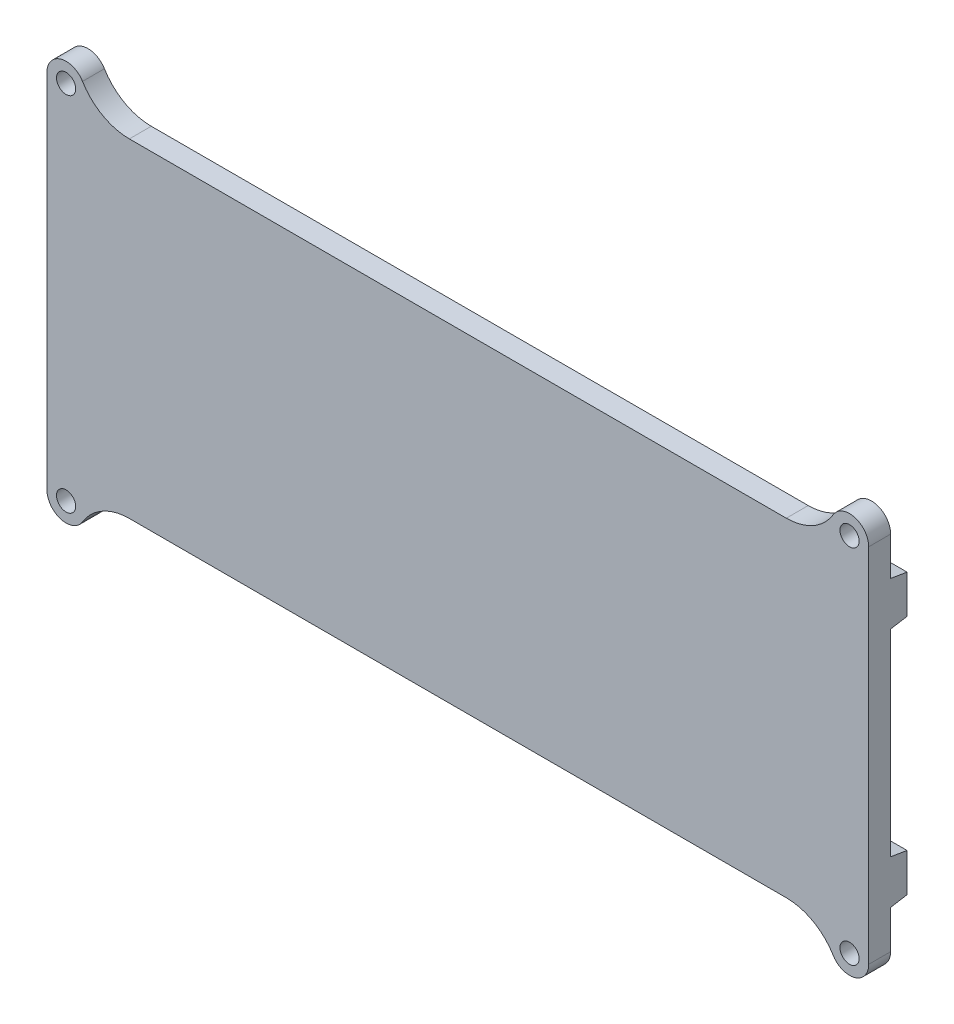
from build123d import *

# Parameters (mm, degrees)
SCHIZZO1_W                   = 150
SCHIZZO1_H                   = 60
ESTRUSIONE_ESTRUSIONE1_DEPTH = 4
SCHIZZO5_R                   = 1.75
ESTRUSIONE_ESTRUSIONE3_DEPTH = 4
SPECCHIA6_COPY_1_SKETCH_R    = 1.75
SPECCHIA6_COPY_1_DEPTH       = 4
RACCORDO2_R                  = 10
ESTRUSIONE_ESTRUSIONE4_DEPTH = 4
SPECCHIA8_COPY_1_DEPTH       = 4


with BuildPart() as part:
    # Schizzo1 → Estrusione-Estrusione1 (new body)
    with BuildSketch(Plane.XY):
        Rectangle(SCHIZZO1_W, SCHIZZO1_H)
    extrude(amount=ESTRUSIONE_ESTRUSIONE1_DEPTH)

    # Schizzo5 → Estrusione-Estrusione3 (add)
    with BuildSketch(Plane(origin=(0, 0, 0), x_dir=(-1, 0, 0), z_dir=(0, 0, -1))):
        with BuildLine():
            Line((-75, 30), (-68, 30))
            Line((-68, 30), (-68, 33))
            ThreePointArc((-68, 33), (-71.5, 36.5), (-75, 33))
            Line((-75, 33), (-75, 30))
        make_face()
        with Locations((-71.5, 33)):
            Circle(SCHIZZO5_R, mode=Mode.SUBTRACT)
    estrusione_estrusione3 = extrude(amount=-ESTRUSIONE_ESTRUSIONE3_DEPTH)

    # Specchia5: Estrusione-Estrusione3 across plane
    add(estrusione_estrusione3.mirror(Plane(origin=(0, 0, 0), x_dir=(0, 0, 1), z_dir=(1, 0, 0))))

    # Specchia6: Estrusione-Estrusione3 across plane
    add(estrusione_estrusione3.mirror(Plane.ZX))

    # Specchia6 copy 1 sketch → Specchia6 copy 1 (add)
    with BuildSketch(Plane(origin=(0, 0, 0), x_dir=(1, 0, 0), z_dir=(0, 0, -1))):
        with BuildLine():
            Line((-75, 30), (-68, 30))
            Line((-68, 30), (-68, 33))
            ThreePointArc((-68, 33), (-71.5, 36.5), (-75, 33))
            Line((-75, 33), (-75, 30))
        make_face()
        with Locations((-71.5, 33)):
            Circle(SPECCHIA6_COPY_1_SKETCH_R, mode=Mode.SUBTRACT)
    extrude(amount=-SPECCHIA6_COPY_1_DEPTH)

    # Raccordo2
    raccordo2_edges = [part.edges().sort_by_distance(p)[0] for p in [
        (68, -30, 2),
        (-68, -30, 2),
        (68, 30, 2),
        (-68, 30, 2),
    ]]
    fillet(raccordo2_edges, radius=RACCORDO2_R)

    # Schizzo6 → Estrusione-Estrusione4 (add)
    with BuildSketch(Plane(origin=(75, 0, 0), x_dir=(0, 0, -1), z_dir=(1, 0, 0))):
        Polygon((0, -26), (3, -25.5), (3, -18.5), (0, -18), align=None)
    estrusione_estrusione4 = extrude(amount=-ESTRUSIONE_ESTRUSIONE4_DEPTH)

    # Specchia7: Estrusione-Estrusione4 across plane
    add(estrusione_estrusione4.mirror(Plane(origin=(0, 0, 0), x_dir=(0, 0, 1), z_dir=(1, 0, 0))))

    # Specchia8: Estrusione-Estrusione4 across plane
    add(estrusione_estrusione4.mirror(Plane.ZX))

    # Specchia8 copy 1 sketch → Specchia8 copy 1 (add)
    with BuildSketch(Plane(origin=(-75, 0, 0), x_dir=(0, 0, -1), z_dir=(-1, 0, 0))):
        Polygon((0, -26), (3, -25.5), (3, -18.5), (0, -18), align=None)
    extrude(amount=-SPECCHIA8_COPY_1_DEPTH)


solid = part.part
